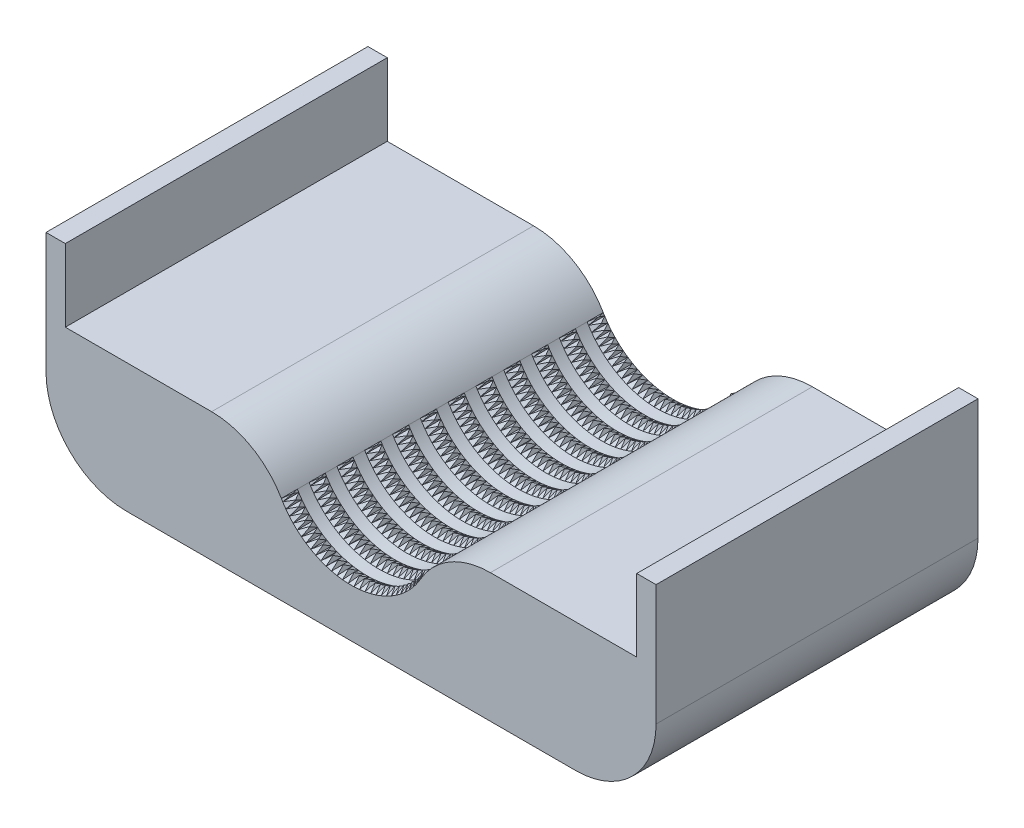
from build123d import *

# Parameters (mm, degrees)
BOSS_EXTRUDE1_DEPTH = 40
CUT_EXTRUDE1_DEPTH  = 41
CUT_EXTRUDE2_DEPTH  = 41


with BuildPart() as part:
    # Sketch1 → Boss-Extrude1 (new body)
    with BuildSketch(Plane.XY):
        with BuildLine():
            Line((-17.320508076, 0), (-35.5, 0))
            Line((-35.5, 0), (-35.5, 9))
            Line((-35.5, 9), (-37.9, 9))
            Line((-37.9, 9), (-37.9, -6))
            ThreePointArc((-37.9, -6), (-34.971067812, -13.071067812), (-27.9, -16))
            Line((-27.9, -16), (27.9, -16))
            ThreePointArc((27.9, -16), (34.971067812, -13.071067812), (37.9, -6))
            Line((37.9, -6), (37.9, 9))
            Line((37.9, 9), (35.5, 9))
            Line((35.5, 9), (35.5, 0))
            Line((35.5, 0), (17.320508076, 0))
            ThreePointArc((17.320508076, 0), (12.320508076, -1.339745962), (8.660254038, -5))
            ThreePointArc((8.660254038, -5), (0, -10), (-8.660254038, -5))
            ThreePointArc((-8.660254038, -5), (-12.320508076, -1.339745962), (-17.320508076, 0))
        make_face()
    extrude(amount=BOSS_EXTRUDE1_DEPTH)

    # Sketch2 → Revolve1 (revolve)
    with BuildSketch(Plane(origin=(0, 0, 0), x_dir=(0, 0, -1), z_dir=(1, 0, 0)), mode=Mode.PRIVATE) as revolve1_sk:
        Polygon((-2, -10), (-1, -9.5), (0, -10), align=None)
        Polygon((-5.454545455, -10), (-4.454545455, -9.5), (-3.454545455, -10), align=None)
        Polygon((-8.909090909, -10), (-7.909090909, -9.5), (-6.909090909, -10), align=None)
        Polygon((-12.363636364, -10), (-11.363636364, -9.5), (-10.363636364, -10), align=None)
        Polygon((-15.818181818, -10), (-14.818181818, -9.5), (-13.818181818, -10), align=None)
        Polygon((-19.272727273, -10), (-18.272727273, -9.5), (-17.272727273, -10), align=None)
        Polygon((-22.727272727, -10), (-21.727272727, -9.5), (-20.727272727, -10), align=None)
        Polygon((-26.181818182, -10), (-25.181818182, -9.5), (-24.181818182, -10), align=None)
        Polygon((-29.636363636, -10), (-28.636363636, -9.5), (-27.636363636, -10), align=None)
        Polygon((-33.090909091, -10), (-32.090909091, -9.5), (-31.090909091, -10), align=None)
        Polygon((-36.545454545, -10), (-35.545454545, -9.5), (-34.545454545, -10), align=None)
        Polygon((-40, -10), (-39, -9.5), (-38, -10), align=None)
    revolve(revolve1_sk.sketch.rotate(Axis((0, 0, 0), (0, 0, -1)), 60), axis=Axis((0, 0, 0), (0, 0, -1)))  # turned: the seam where the file's is

    # Sketch3 → Cut-Extrude1 (cut, through all)
    with BuildSketch(Plane.XY.offset(40)):
        with BuildLine():
            Line((-8.660254038, -5), (0, 0))
            Line((0, 0), (8.660254038, -5))
            ThreePointArc((8.660254038, -5), (0, 10), (-8.660254038, -5))
        make_face()
    extrude(amount=-CUT_EXTRUDE1_DEPTH, mode=Mode.SUBTRACT)

    # Sketch4 → Cut-Extrude2 (cut, through all)
    with BuildSketch(Plane.XY.offset(40)):
        with BuildLine():
            Line((-8.227241336, -4.75), (-8.490024538, -5.283889037))
            Line((-8.490024538, -5.283889037), (-7.894967805, -5.283889037))
            ThreePointArc((-7.894967805, -5.283889037), (-8.065523311, -5.019694585), (-8.227241336, -4.75))
        make_face()
        with BuildLine():
            Line((-7.875196115, -5.313312164), (-8.100028446, -5.864259473))
            Line((-8.100028446, -5.864259473), (-7.50642641, -5.822676579))
            ThreePointArc((-7.50642641, -5.822676579), (-7.695027024, -5.571046499), (-7.875196115, -5.313312164))
        make_face()
        with BuildLine():
            Line((-7.48464695, -5.850646122), (-7.670429146, -6.415957974))
            Line((-7.670429146, -6.415957974), (-7.081184085, -6.332995496))
            ThreePointArc((-7.081184085, -6.332995496), (-7.286907689, -6.095160075), (-7.48464695, -5.850646122))
        make_face()
        with BuildLine():
            Line((-7.05750334, -6.359374702), (-7.203327062, -6.936287137))
            Line((-7.203327062, -6.936287137), (-6.621319953, -6.812350701))
            ThreePointArc((-6.621319953, -6.812350701), (-6.843160709, -6.58947278), (-7.05750334, -6.359374702))
        make_face()
        with BuildLine():
            Line((-6.595853706, -6.837010596), (-6.701005982, -7.422702933))
            Line((-6.701005982, -7.422702933), (-6.129082414, -7.258398498))
            ThreePointArc((-6.129082414, -7.258398498), (-6.365955683, -7.051567786), (-6.595853706, -6.837010596))
        make_face()
        with BuildLine():
            Line((-6.101955175, -7.281218514), (-6.165921888, -7.872827146))
            Line((-6.165921888, -7.872827146), (-5.606878149, -7.66895804))
            ThreePointArc((-5.606878149, -7.66895804), (-5.857625794, -7.479185789), (-6.101955175, -7.281218514))
        make_face()
        with BuildLine():
            Line((-5.578222551, -7.689826602), (-5.60069095, -8.284458998))
            Line((-5.60069095, -8.284458998), (-5.057260354, -8.042021992))
            ThreePointArc((-5.057260354, -8.042021992), (-5.320656402, -7.870236048), (-5.578222551, -7.689826602))
        make_face()
        with BuildLine():
            Line((-5.027216502, -8.060837069), (-5.008076733, -8.655585909))
            Line((-5.008076733, -8.655585909), (-4.482916258, -8.375766342))
            ThreePointArc((-4.482916258, -8.375766342), (-4.757672896, -8.222806614), (-5.027216502, -8.060837069))
        make_face()
        with BuildLine():
            Line((-4.451631044, -8.392435942), (-4.390976687, -8.984393343))
            Line((-4.390976687, -8.984393343), (-3.886653984, -8.668559327))
            ThreePointArc((-3.886653984, -8.668559327), (-4.171427853, -8.535173675), (-4.451631044, -8.392435942))
        make_face()
        with BuildLine():
            Line((-3.854280369, -8.683001948), (-3.75240798, -9.269273669))
            Line((-3.75240798, -9.269273669), (-3.271388816, -8.918969403))
            ThreePointArc((-3.271388816, -8.918969403), (-3.564787581, -8.805809986), (-3.854280369, -8.683001948))
        make_face()
        with BuildLine():
            Line((-3.238085085, -8.931114431), (-3.095492744, -9.508834033))
            Line((-3.095492744, -9.508834033), (-2.640128952, -9.125772248))
            ThreePointArc((-2.640128952, -9.125772248), (-2.940718107, -9.033392332), (-3.238085085, -8.931114431))
        make_face()
        with BuildLine():
            Line((-2.606057936, -9.135560302), (-2.423442815, -9.70190316))
            Line((-2.423442815, -9.70190316), (-1.995960791, -9.287956746))
            ThreePointArc((-1.995960791, -9.287956746), (-2.302270675, -9.216808002), (-2.606057936, -9.135560302))
        make_face()
        with BuildLine():
            Line((-1.961289071, -9.295339971), (-1.739544025, -9.847537082))
            Line((-1.739544025, -9.847537082), (-1.342033842, -9.404729936))
            ThreePointArc((-1.342033842, -9.404729936), (-1.652566824, -9.355160228), (-1.961289071, -9.295339971))
        make_face()
        with BuildLine():
            Line((-1.306930938, -9.409672233), (-1.047140138, -9.945023757))
            Line((-1.047140138, -9.945023757), (-0.68154533, -9.475520881))
            ThreePointArc((-0.68154533, -9.475520881), (-0.994783131, -9.447772569), (-1.306930938, -9.409672233))
        make_face()
        with BuildLine():
            Line((-0.646182869, -9.477998085), (-0.349616502, -9.993886546))
            Line((-0.349616502, -9.993886546), (-0.017724561, -9.499983465))
            ThreePointArc((-0.017724561, -9.499983465), (-0.332135677, -9.494192219), (-0.646182869, -9.477998085))
        make_face()
        with BuildLine():
            Line((0.017724561, -9.499983465), (0.349616502, -9.993886546))
            Line((0.349616502, -9.993886546), (0.646182869, -9.477998085))
            ThreePointArc((0.646182869, -9.477998085), (0.332135677, -9.494192219), (0.017724561, -9.499983465))
        make_face()
        with BuildLine():
            Line((0.68154533, -9.475520881), (1.047140138, -9.945023757))
            Line((1.047140138, -9.945023757), (1.306930938, -9.409672233))
            ThreePointArc((1.306930938, -9.409672233), (0.994783131, -9.447772569), (0.68154533, -9.475520881))
        make_face()
        with BuildLine():
            Line((1.342033842, -9.404729936), (1.739544025, -9.847537082))
            Line((1.739544025, -9.847537082), (1.961289071, -9.295339971))
            ThreePointArc((1.961289071, -9.295339971), (1.652566824, -9.355160228), (1.342033842, -9.404729936))
        make_face()
        with BuildLine():
            Line((1.995960791, -9.287956746), (2.423442815, -9.70190316))
            Line((2.423442815, -9.70190316), (2.606057936, -9.135560302))
            ThreePointArc((2.606057936, -9.135560302), (2.302270675, -9.216808002), (1.995960791, -9.287956746))
        make_face()
        with BuildLine():
            Line((2.640128952, -9.125772248), (3.095492744, -9.508834033))
            Line((3.095492744, -9.508834033), (3.238085085, -8.931114431))
            ThreePointArc((3.238085085, -8.931114431), (2.940718107, -9.033392332), (2.640128952, -9.125772248))
        make_face()
        with BuildLine():
            Line((3.271388816, -8.918969403), (3.75240798, -9.269273669))
            Line((3.75240798, -9.269273669), (3.854280369, -8.683001948))
            ThreePointArc((3.854280369, -8.683001948), (3.564787581, -8.805809986), (3.271388816, -8.918969403))
        make_face()
        with BuildLine():
            Line((3.886653984, -8.668559327), (4.390976687, -8.984393343))
            Line((4.390976687, -8.984393343), (4.451631044, -8.392435942))
            ThreePointArc((4.451631044, -8.392435942), (4.171427853, -8.535173675), (3.886653984, -8.668559327))
        make_face()
        with BuildLine():
            Line((4.482916258, -8.375766342), (5.008076733, -8.655585909))
            Line((5.008076733, -8.655585909), (5.027216502, -8.060837069))
            ThreePointArc((5.027216502, -8.060837069), (4.757672896, -8.222806614), (4.482916258, -8.375766342))
        make_face()
        with BuildLine():
            Line((5.057260354, -8.042021992), (5.60069095, -8.284458998))
            Line((5.60069095, -8.284458998), (5.578222551, -7.689826602))
            ThreePointArc((5.578222551, -7.689826602), (5.320656402, -7.870236048), (5.057260354, -8.042021992))
        make_face()
        with BuildLine():
            Line((5.606878149, -7.66895804), (6.165921888, -7.872827146))
            Line((6.165921888, -7.872827146), (6.101955175, -7.281218514))
            ThreePointArc((6.101955175, -7.281218514), (5.857625794, -7.479185789), (5.606878149, -7.66895804))
        make_face()
        with BuildLine():
            Line((6.129082414, -7.258398498), (6.701005982, -7.422702933))
            Line((6.701005982, -7.422702933), (6.595853706, -6.837010596))
            ThreePointArc((6.595853706, -6.837010596), (6.365955683, -7.051567786), (6.129082414, -7.258398498))
        make_face()
        with BuildLine():
            Line((6.621319953, -6.812350701), (7.203327062, -6.936287137))
            Line((7.203327062, -6.936287137), (7.05750334, -6.359374702))
            ThreePointArc((7.05750334, -6.359374702), (6.843160709, -6.58947278), (6.621319953, -6.812350701))
        make_face()
        with BuildLine():
            Line((7.081184085, -6.332995496), (7.670429146, -6.415957974))
            Line((7.670429146, -6.415957974), (7.48464695, -5.850646122))
            ThreePointArc((7.48464695, -5.850646122), (7.286907689, -6.095160075), (7.081184085, -6.332995496))
        make_face()
        with BuildLine():
            Line((7.50642641, -5.822676579), (8.100028446, -5.864259473))
            Line((8.100028446, -5.864259473), (7.875196115, -5.313312164))
            ThreePointArc((7.875196115, -5.313312164), (7.695027024, -5.571046499), (7.50642641, -5.822676579))
        make_face()
        with BuildLine():
            Line((7.894967805, -5.283889037), (8.490024538, -5.283889037))
            Line((8.490024538, -5.283889037), (8.227241336, -4.75))
            ThreePointArc((8.227241336, -4.75), (8.065523311, -5.019694585), (7.894967805, -5.283889037))
        make_face()
        with BuildLine():
            Line((8.244908588, -4.719267144), (8.838510624, -4.677684251))
            Line((8.838510624, -4.677684251), (8.53906137, -4.163463813))
            ThreePointArc((8.53906137, -4.163463813), (8.396585093, -4.443800038), (8.244908588, -4.719267144))
        make_face()
    extrude(amount=-CUT_EXTRUDE2_DEPTH, mode=Mode.SUBTRACT)


solid = part.part
